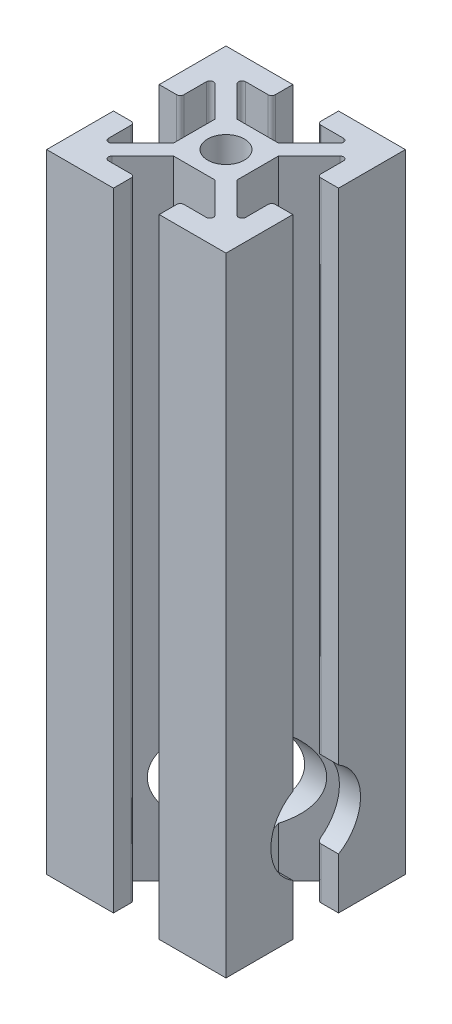
from build123d import *

# Parameters (mm, degrees)
SKETCH1_W           = 25.4
SKETCH1_H           = 25.4
BOSS_EXTRUDE1_DEPTH = 88.9
SKETCH2_R           = 6.35
CUT_EXTRUDE1_DEPTH  = 26.4
SKETCH4_R           = 2.6035
CUT_EXTRUDE2_DEPTH  = 89.9


with BuildPart() as part:
    # Sketch1 → Boss-Extrude1 (new body)
    with BuildSketch(Plane(origin=(0, 0, 0), x_dir=(1, 0, 0), z_dir=(0, 1, 0))):
        Rectangle(SKETCH1_W, SKETCH1_H)
    extrude(amount=BOSS_EXTRUDE1_DEPTH)

    # Sketch2 → Cut-Extrude1 (cut, through all)
    with BuildSketch(Plane(origin=(12.7, 0, 0), x_dir=(0, 0, -1), z_dir=(1, 0, 0))):
        with Locations((0, 12.7)):
            Circle(SKETCH2_R)
    extrude(amount=-CUT_EXTRUDE1_DEPTH, mode=Mode.SUBTRACT)

    # Sketch4 → Cut-Extrude2 (cut, through all)
    with BuildSketch(Plane.XZ):
        Circle(SKETCH4_R)
        with BuildLine():
            Line((-3.2385, 12.7), (3.2385, 12.7))
            Line((3.2385, 12.7), (3.2385, 10.218485055))
            ThreePointArc((3.2385, 10.218485055), (3.387289755, 9.85927481), (3.7465, 9.710485055))
            Line((3.7465, 9.710485055), (6.9215, 9.710485055))
            ThreePointArc((6.9215, 9.710485055), (7.390830803, 9.396888238), (7.280710245, 8.84327481))
            Line((7.280710245, 8.84327481), (2.945935435, 4.5085))
            Line((2.945935435, 4.5085), (-2.945935435, 4.5085))
            Line((-2.945935435, 4.5085), (-7.280710245, 8.84327481))
            ThreePointArc((-7.280710245, 8.84327481), (-7.390830803, 9.396888238), (-6.9215, 9.710485055))
            Line((-6.9215, 9.710485055), (-3.7465, 9.710485055))
            ThreePointArc((-3.7465, 9.710485055), (-3.387289755, 9.85927481), (-3.2385, 10.218485055))
            Line((-3.2385, 10.218485055), (-3.2385, 12.7))
        make_face()
        with BuildLine():
            Line((12.7, 3.2385), (12.7, -3.2385))
            Line((12.7, -3.2385), (10.218485055, -3.2385))
            ThreePointArc((10.218485055, -3.2385), (9.85927481, -3.387289755), (9.710485055, -3.7465))
            Line((9.710485055, -3.7465), (9.710485055, -6.9215))
            ThreePointArc((9.710485055, -6.9215), (9.396888238, -7.390830803), (8.84327481, -7.280710245))
            Line((8.84327481, -7.280710245), (4.5085, -2.945935435))
            Line((4.5085, -2.945935435), (4.5085, 2.945935435))
            Line((4.5085, 2.945935435), (8.84327481, 7.280710245))
            ThreePointArc((8.84327481, 7.280710245), (9.396888238, 7.390830803), (9.710485055, 6.9215))
            Line((9.710485055, 6.9215), (9.710485055, 3.7465))
            ThreePointArc((9.710485055, 3.7465), (9.85927481, 3.387289755), (10.218485055, 3.2385))
            Line((10.218485055, 3.2385), (12.7, 3.2385))
        make_face()
        with BuildLine():
            Line((3.2385, -12.7), (-3.2385, -12.7))
            Line((-3.2385, -12.7), (-3.2385, -10.218485055))
            ThreePointArc((-3.2385, -10.218485055), (-3.387289755, -9.85927481), (-3.7465, -9.710485055))
            Line((-3.7465, -9.710485055), (-6.9215, -9.710485055))
            ThreePointArc((-6.9215, -9.710485055), (-7.390830803, -9.396888238), (-7.280710245, -8.84327481))
            Line((-7.280710245, -8.84327481), (-2.945935435, -4.5085))
            Line((-2.945935435, -4.5085), (2.945935435, -4.5085))
            Line((2.945935435, -4.5085), (7.280710245, -8.84327481))
            ThreePointArc((7.280710245, -8.84327481), (7.390830803, -9.396888238), (6.9215, -9.710485055))
            Line((6.9215, -9.710485055), (3.7465, -9.710485055))
            ThreePointArc((3.7465, -9.710485055), (3.387289755, -9.85927481), (3.2385, -10.218485055))
            Line((3.2385, -10.218485055), (3.2385, -12.7))
        make_face()
        with BuildLine():
            Line((-12.7, -3.2385), (-12.7, 3.2385))
            Line((-12.7, 3.2385), (-10.218485055, 3.2385))
            ThreePointArc((-10.218485055, 3.2385), (-9.85927481, 3.387289755), (-9.710485055, 3.7465))
            Line((-9.710485055, 3.7465), (-9.710485055, 6.9215))
            ThreePointArc((-9.710485055, 6.9215), (-9.396888238, 7.390830803), (-8.84327481, 7.280710245))
            Line((-8.84327481, 7.280710245), (-4.5085, 2.945935435))
            Line((-4.5085, 2.945935435), (-4.5085, -2.945935435))
            Line((-4.5085, -2.945935435), (-8.84327481, -7.280710245))
            ThreePointArc((-8.84327481, -7.280710245), (-9.396888238, -7.390830803), (-9.710485055, -6.9215))
            Line((-9.710485055, -6.9215), (-9.710485055, -3.7465))
            ThreePointArc((-9.710485055, -3.7465), (-9.85927481, -3.387289755), (-10.218485055, -3.2385))
            Line((-10.218485055, -3.2385), (-12.7, -3.2385))
        make_face()
    extrude(amount=-CUT_EXTRUDE2_DEPTH, mode=Mode.SUBTRACT)


solid = part.part
